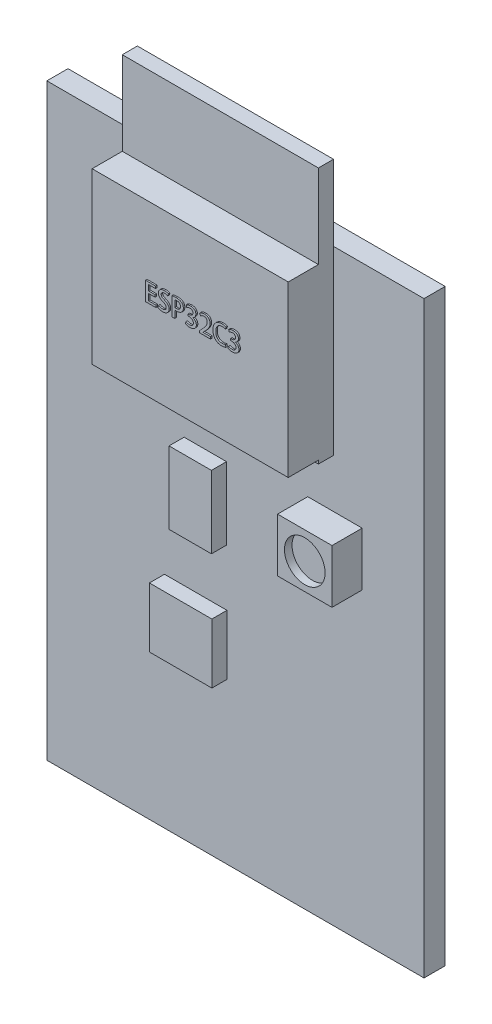
from build123d import *

# Parameters (mm, degrees)
ESQUISSE1_W             = 25
ESQUISSE1_H             = 39
BOSS_EXTRU_1_DEPTH      = 1.4
BOSS_EXTRU_2_DEPTH      = 1
ESQUISSE3_W             = 13
ESQUISSE3_H             = 11.227478687
BOSS_EXTRU_3_DEPTH      = 2
ESQUISSE4_W             = 2.809980336
ESQUISSE4_H             = 4.791755942
BOSS_EXTRU_4_DEPTH      = 1
ESQUISSE5_W             = 4.141023654
ESQUISSE5_H             = 3.963551212
BOSS_EXTRU_5_DEPTH      = 1
ESQUISSE6_W             = 3.608606328
ESQUISSE6_H             = 3.549448846
BOSS_EXTRU_6_DEPTH      = 2
ESQUISSE7_R             = 1.346751514
ENL_V_MAT_EXTRU_1_DEPTH = 0.5
BOSS_EXTRU_7_DEPTH      = 0.1


with BuildPart() as part:
    # Esquisse1 → Boss.-Extru.1 (new body)
    with BuildSketch(Plane.XY):
        with Locations((12.5, 19.5)):
            Rectangle(ESQUISSE1_W, ESQUISSE1_H)
    extrude(amount=BOSS_EXTRU_1_DEPTH)

    # Esquisse2 → Boss.-Extru.2 (add)
    with BuildSketch(Plane.XY.offset(1.4)):
        Polygon((12.5, 44), (19, 44), (19, 27), (6, 27), (6, 44), align=None)
    extrude(amount=BOSS_EXTRU_2_DEPTH)

    # Esquisse3 → Boss.-Extru.3 (add)
    with BuildSketch(Plane.XY.offset(2.4)):
        with Locations((12.5, 32.841661825)):
            Rectangle(ESQUISSE3_W, ESQUISSE3_H)
    extrude(amount=BOSS_EXTRU_3_DEPTH)

    # Esquisse4 → Boss.-Extru.4 (add)
    with BuildSketch(Plane.XY.offset(1.4)):
        with Locations((10.503435024, 20.698535423)):
            Rectangle(ESQUISSE4_W, ESQUISSE4_H)
    extrude(amount=BOSS_EXTRU_4_DEPTH)

    # Esquisse5 → Boss.-Extru.5 (add)
    with BuildSketch(Plane.XY.offset(1.4)):
        with Locations((9.867492106, 12.593960557)):
            Rectangle(ESQUISSE5_W, ESQUISSE5_H)
    extrude(amount=BOSS_EXTRU_5_DEPTH)

    # Esquisse6 → Boss.-Extru.6 (add)
    with BuildSketch(Plane.XY.offset(1.4)):
        with Locations((19.096059106, 22)):
            Rectangle(ESQUISSE6_W, ESQUISSE6_H)
    extrude(amount=BOSS_EXTRU_6_DEPTH)

    # Esquisse7 → Enlèv. mat.-Extru.1 (cut)
    with BuildSketch(Plane.XY.offset(3.4)):
        with Locations((19.096059106, 21.974927167)):
            Circle(ESQUISSE7_R)
    extrude(amount=-ENL_V_MAT_EXTRU_1_DEPTH, mode=Mode.SUBTRACT)

    # Esquisse8 → Boss.-Extru.7 (add)
    with BuildSketch(Plane.XY.offset(4.4)):
        Polygon((10.324274962, 32.843582432), (9.836071083, 32.843582432), (9.836071083, 33.266659172), (10.270750948, 33.266659172), (10.270750948, 33.414255694), (9.836071083, 33.414255694), (9.836071083, 33.77726154), (10.296701985, 33.77726154), (10.296701985, 33.924858061), (9.645533488, 33.924858061), (9.645533488, 32.695985911), (10.324274962, 32.695985911), align=None)
        with BuildLine():
            add(Edge.make_bspline(
                [(11.156073198, 33.901634395), (11.148806667, 33.90496295), (11.133481415, 33.911982936), (11.10837148, 33.921338581), (11.080088444, 33.930151407), (11.048646525, 33.93837266), (11.014149757, 33.945500766), (10.976592052, 33.950502041), (10.936020986, 33.953848147), (10.907968138, 33.954459306), (10.893412674, 33.954776411)],
                knots=[0, 0, 0, 0, 2.3972e-05, 5.0557e-05, 8.0317e-05, 0.000112815, 0.00014802, 0.000185918, 0.000226411, 0.000270079, 0.000270079, 0.000270079, 0.000270079], degree=3))
            add(Edge.make_bspline(
                [(10.893412674, 33.954776411), (10.878070628, 33.954266307), (10.848178525, 33.953272432), (10.8046434, 33.948589215), (10.763610972, 33.941105334), (10.725099188, 33.930901658), (10.689132518, 33.917671301), (10.655642631, 33.901681303), (10.624622064, 33.882959058), (10.596362877, 33.861504179), (10.570999352, 33.837870596), (10.548858082, 33.812187014), (10.529872337, 33.784785439), (10.514264075, 33.755425262), (10.502010405, 33.72416996), (10.493512939, 33.691048326), (10.487537356, 33.656274803), (10.486713418, 33.632390871), (10.486291577, 33.620162761)],
                knots=[0, 0, 0, 0, 4.604e-05, 8.9704e-05, 0.000131218, 0.000171062, 0.000209073, 0.000246017, 0.000282235, 0.000317574, 0.000352272, 0.000386046, 0.000419111, 0.000452073, 0.000485582, 0.000519561, 0.000554512, 0.000591179, 0.000591179, 0.000591179, 0.000591179], degree=3))
            add(Edge.make_bspline(
                [(10.486291577, 33.620162761), (10.486756044, 33.60982672), (10.487671023, 33.589465162), (10.491799884, 33.559555397), (10.499025609, 33.531036067), (10.508335991, 33.503516579), (10.520626882, 33.477347755), (10.535169154, 33.452266109), (10.552557978, 33.428662646), (10.572253772, 33.406204248), (10.594216055, 33.384889134), (10.617884989, 33.364418486), (10.643605449, 33.345181717), (10.67107081, 33.326934425), (10.700251916, 33.309493924), (10.731295002, 33.293114821), (10.764052207, 33.277564387), (10.78683064, 33.26838179), (10.798378643, 33.263726481)],
                knots=[0, 0, 0, 0, 3.1031e-05, 6.113e-05, 9.0382e-05, 0.000119175, 0.00014815, 0.000176965, 0.000206018, 0.00023595, 0.000266482, 0.000297762, 0.000329769, 0.000362765, 0.000396649, 0.000431709, 0.000468028, 0.000505373, 0.000505373, 0.000505373, 0.000505373], degree=3))
            add(Edge.make_bspline(
                [(10.798378643, 33.263726481), (10.807407689, 33.25997084), (10.824902148, 33.252694002), (10.84988054, 33.240805241), (10.873060364, 33.228999184), (10.89436976, 33.216709249), (10.913781159, 33.204080688), (10.931432468, 33.191274888), (10.947071004, 33.177972412), (10.961013638, 33.164443857), (10.973059766, 33.150134629), (10.983774782, 33.135461059), (10.992377864, 33.119741844), (10.999847632, 33.103607445), (11.005124204, 33.086443648), (11.009226672, 33.068745457), (11.011267242, 33.050163109), (11.011538585, 33.037604205), (11.011677246, 33.03118642)],
                knots=[0, 0, 0, 0, 2.9332e-05, 5.6834e-05, 8.2966e-05, 0.000107356, 0.000130591, 0.000152415, 0.000172726, 0.000192139, 0.000210617, 0.000228784, 0.000246539, 0.000264289, 0.000282025, 0.000300299, 0.000318724, 0.000337978, 0.000337978, 0.000337978, 0.000337978], degree=3))
            add(Edge.make_bspline(
                [(11.011677246, 33.03118642), (11.011399209, 33.024218202), (11.010856508, 33.010616926), (11.008159661, 32.990741197), (11.003054836, 32.97209707), (10.996542057, 32.954344135), (10.98807234, 32.937628173), (10.977683015, 32.922023991), (10.965307415, 32.907623096), (10.951277578, 32.894287661), (10.93548469, 32.882154135), (10.91776131, 32.872003336), (10.898622568, 32.862886927), (10.87773124, 32.855743085), (10.85526258, 32.850150232), (10.831204453, 32.845877271), (10.805467925, 32.843386105), (10.787746113, 32.84281753), (10.778667881, 32.842526269)],
                knots=[0, 0, 0, 0, 2.0917e-05, 4.0828e-05, 6.0009e-05, 7.8794e-05, 9.7474e-05, 0.000116087, 0.000134896, 0.000154315, 0.000174074, 0.000194477, 0.000215472, 0.000237587, 0.000260579, 0.000284883, 0.000310824, 0.000338069, 0.000338069, 0.000338069, 0.000338069], degree=3))
            add(Edge.make_bspline(
                [(10.778667881, 32.842526269), (10.765752057, 32.842906029), (10.74017485, 32.843658068), (10.702299788, 32.847712925), (10.665340916, 32.85420387), (10.62972148, 32.863527262), (10.59560825, 32.874025383), (10.563971298, 32.886602425), (10.534581531, 32.900040524), (10.516484988, 32.910586168), (10.507644903, 32.915737671)],
                knots=[0, 0, 0, 0, 3.8752e-05, 7.6741e-05, 0.000114163, 0.000151213, 0.000187132, 0.000221164, 0.000253286, 0.000283964, 0.000283964, 0.000283964, 0.000283964], degree=3))
            Line((10.507644903, 32.915737671), (10.465440783, 32.75736091))
            add(Edge.make_bspline(
                [(10.465440783, 32.75736091), (10.473928872, 32.752079704), (10.491787056, 32.740968518), (10.522258257, 32.727429262), (10.556799533, 32.714727798), (10.595266189, 32.703775717), (10.636309916, 32.694511539), (10.678900439, 32.68735393), (10.722657699, 32.683114002), (10.752221482, 32.682390285), (10.767169936, 32.68202435)],
                knots=[0, 0, 0, 0, 2.9959e-05, 6.3032e-05, 9.978e-05, 0.000140328, 0.000182908, 0.00022596, 0.000269809, 0.000314658, 0.000314658, 0.000314658, 0.000314658], degree=3))
            add(Edge.make_bspline(
                [(10.767169936, 32.68202435), (10.784314418, 32.682569781), (10.817668988, 32.683630917), (10.866130299, 32.689106104), (10.911501418, 32.697415444), (10.953688412, 32.708873279), (10.992799118, 32.723437961), (11.02869063, 32.741286501), (11.061625101, 32.761944915), (11.091048701, 32.785775465), (11.117066458, 32.812132597), (11.139935969, 32.840306846), (11.15937102, 32.870318903), (11.175196351, 32.902201246), (11.187387701, 32.936010555), (11.196299444, 32.971528671), (11.201847615, 33.008877801), (11.202556848, 33.034373961), (11.202918568, 33.047377403)],
                knots=[0, 0, 0, 0, 5.1442e-05, 0.000100081, 0.00014615, 0.000189698, 0.000231059, 0.000271146, 0.000309749, 0.000347459, 0.00038446, 0.000420668, 0.00045614, 0.000491505, 0.00052721, 0.000563747, 0.000601213, 0.00064021, 0.00064021, 0.00064021, 0.00064021], degree=3))
            add(Edge.make_bspline(
                [(11.202918568, 33.047377403), (11.202808349, 33.057792263), (11.202592199, 33.078216741), (11.198820859, 33.108169692), (11.193264526, 33.136987559), (11.185412662, 33.16461898), (11.174823449, 33.190881052), (11.162511638, 33.216181588), (11.147387619, 33.240032659), (11.130109172, 33.262796604), (11.110368997, 33.284412964), (11.088627105, 33.305655363), (11.064046711, 33.325738846), (11.0372426, 33.345224712), (11.0081483, 33.364035842), (10.976449031, 33.381799667), (10.942584304, 33.399265371), (10.918737459, 33.409730127), (10.906553182, 33.415076975)],
                knots=[0, 0, 0, 0, 3.1223e-05, 6.1231e-05, 9.0407e-05, 0.000119222, 0.00014724, 0.000175259, 0.000203515, 0.000231815, 0.00026089, 0.000291258, 0.000322925, 0.000356014, 0.000390641, 0.00042679, 0.000464989, 0.000504897, 0.000504897, 0.000504897, 0.000504897], degree=3))
            add(Edge.make_bspline(
                [(10.906553182, 33.415076975), (10.896976911, 33.4190683), (10.878322738, 33.426843234), (10.851703015, 33.439431675), (10.826718035, 33.451434011), (10.803981004, 33.463897242), (10.783221687, 33.476442388), (10.76424258, 33.488723382), (10.747286494, 33.501147308), (10.73229342, 33.513739787), (10.718905108, 33.526600601), (10.707683787, 33.540596108), (10.697881698, 33.55517006), (10.69008856, 33.570786536), (10.684277798, 33.58729677), (10.680038628, 33.604582005), (10.677342777, 33.622658564), (10.677157546, 33.635014461), (10.677063596, 33.641281435)],
                knots=[0, 0, 0, 0, 3.1119e-05, 6.0619e-05, 8.8324e-05, 0.000114262, 0.000138367, 0.000161081, 0.00018206, 0.000201378, 0.000219796, 0.000237644, 0.000255086, 0.000272401, 0.000289842, 0.000307485, 0.000325737, 0.000344522, 0.000344522, 0.000344522, 0.000344522], degree=3))
            add(Edge.make_bspline(
                [(10.677063596, 33.641281435), (10.677551109, 33.651517), (10.678524029, 33.671943895), (10.688179296, 33.701720879), (10.704403196, 33.729523753), (10.722564261, 33.750871905), (10.740345871, 33.76633042), (10.755990081, 33.77667051), (10.773479533, 33.785583269), (10.792796616, 33.793110608), (10.81403106, 33.798963661), (10.837229582, 33.802994043), (10.862200296, 33.80620774), (10.879557342, 33.80685), (10.888484983, 33.807180348)],
                knots=[0, 0, 0, 0, 3.0634e-05, 6.1136e-05, 9.2774e-05, 0.000126726, 0.000144695, 0.000163308, 0.000182828, 0.000203483, 0.000225401, 0.000248781, 0.000274074, 0.000300861, 0.000300861, 0.000300861, 0.000300861], degree=3))
            add(Edge.make_bspline(
                [(10.888484983, 33.807180348), (10.90100883, 33.806792894), (10.925329102, 33.80604049), (10.960390918, 33.802329444), (10.992843796, 33.796436606), (11.022447994, 33.788755349), (11.049055235, 33.779792772), (11.072520941, 33.770656649), (11.092843724, 33.761687734), (11.10487713, 33.754937466), (11.110465708, 33.751802493)],
                knots=[0, 0, 0, 0, 3.758e-05, 7.2978e-05, 0.000105656, 0.000136446, 0.000164644, 0.00018983, 0.000211988, 0.000231203, 0.000231203, 0.000231203, 0.000231203], degree=3))
            Line((11.110465708, 33.751802493), (11.156073198, 33.901634395))
        make_face()
        with BuildLine():
            Line((11.387589407, 32.698080591), (11.578127002, 32.698080591))
            Line((11.578127002, 32.698080591), (11.578127002, 33.184574307))
            add(Edge.make_bspline(
                [(11.578127002, 33.184574307), (11.586090065, 33.183161735), (11.602493748, 33.180251877), (11.628065976, 33.177880849), (11.655152299, 33.176395399), (11.673706237, 33.176422184), (11.683251066, 33.176435964)],
                knots=[0, 0, 0, 0, 2.4253e-05, 4.9959e-05, 7.6981e-05, 0.00010561, 0.00010561, 0.00010561, 0.00010561], degree=3))
            add(Edge.make_bspline(
                [(11.683251066, 33.176435964), (11.697730015, 33.176443872), (11.726350277, 33.176459504), (11.768687009, 33.180428483), (11.809959179, 33.186907014), (11.850146773, 33.196518822), (11.889230713, 33.209322032), (11.927295567, 33.224781164), (11.964259309, 33.243175514), (11.999901507, 33.264262178), (12.033174805, 33.288936813), (12.062610772, 33.318066408), (12.087547866, 33.351457132), (12.108393333, 33.388793875), (12.124991791, 33.430046479), (12.137387199, 33.475312346), (12.145646585, 33.524539565), (12.14757121, 33.558807903), (12.148565841, 33.576517502)],
                knots=[0, 0, 0, 0, 4.3416e-05, 8.582e-05, 0.000127407, 0.000168669, 0.000209631, 0.000250678, 0.000291814, 0.000333385, 0.000374778, 0.000415761, 0.000457154, 0.000499387, 0.000543702, 0.000590214, 0.000639939, 0.00069312, 0.00069312, 0.00069312, 0.00069312], degree=3))
            add(Edge.make_bspline(
                [(12.148565841, 33.576517502), (12.147955802, 33.590382856), (12.146764898, 33.617450513), (12.14082913, 33.656740555), (12.131694944, 33.693610003), (12.119301016, 33.728153899), (12.103243669, 33.760122772), (12.084091383, 33.78979844), (12.061570907, 33.81703286), (12.044040208, 33.832807136), (12.035228959, 33.840735574)],
                knots=[0, 0, 0, 0, 4.1614e-05, 8.1237e-05, 0.000118969, 0.000155416, 0.000191095, 0.000226047, 0.000261198, 0.00029672, 0.00029672, 0.00029672, 0.00029672], degree=3))
            add(Edge.make_bspline(
                [(12.035228959, 33.840735574), (12.025319532, 33.848731713), (12.00518891, 33.864975565), (11.970914603, 33.885074679), (11.933275608, 33.902124587), (11.892137233, 33.9162955), (11.847339085, 33.927023552), (11.798962369, 33.934210998), (11.747100723, 33.939168334), (11.711343741, 33.939557596), (11.692871795, 33.939758688)],
                knots=[0, 0, 0, 0, 3.8157e-05, 7.7514e-05, 0.000118781, 0.00016197, 0.000207842, 0.00025676, 0.000308596, 0.000363992, 0.000363992, 0.000363992, 0.000363992], degree=3))
            add(Edge.make_bspline(
                [(11.692871795, 33.939758688), (11.677305833, 33.93947918), (11.646951658, 33.93893413), (11.602671129, 33.937583456), (11.560813749, 33.935505728), (11.521396225, 33.932623), (11.484372742, 33.929460714), (11.449787303, 33.925464631), (11.417705318, 33.920829395), (11.397201154, 33.917130912), (11.387354984, 33.915354887)],
                knots=[0, 0, 0, 0, 4.6705e-05, 9.1077e-05, 0.000132898, 0.00017242, 0.00020964, 0.000244364, 0.000276852, 0.000306866, 0.000306866, 0.000306866, 0.000306866], degree=3))
            Line((11.387354984, 33.915354887), (11.387589407, 32.698080591))
        make_face()
        with BuildLine():
            add(Edge.make_bspline(
                [(11.578127002, 33.781077154), (11.585464044, 33.782522642), (11.602076306, 33.785795461), (11.630475666, 33.788801339), (11.665150046, 33.791100313), (11.690442408, 33.79178951), (11.704135088, 33.792162625)],
                knots=[0, 0, 0, 0, 2.2425e-05, 5.0774e-05, 8.5582e-05, 0.00012667, 0.00012667, 0.00012667, 0.00012667], degree=3))
            add(Edge.make_bspline(
                [(11.704135088, 33.792162625), (11.713448307, 33.791968122), (11.731641959, 33.791588154), (11.758245852, 33.789042364), (11.783414349, 33.784562172), (11.80718779, 33.778464228), (11.829580413, 33.770838555), (11.850438054, 33.761053698), (11.86988743, 33.749635017), (11.887794861, 33.736405), (11.904166479, 33.721682825), (11.918256268, 33.70487485), (11.930387885, 33.686402466), (11.940205011, 33.666099643), (11.947967869, 33.644137981), (11.953571599, 33.620463163), (11.957120587, 33.595081219), (11.957720388, 33.57754618), (11.958028475, 33.568539337)],
                knots=[0, 0, 0, 0, 2.7939e-05, 5.458e-05, 8.0081e-05, 0.000104553, 0.000128152, 0.000150933, 0.000173549, 0.000195701, 0.000217626, 0.000239438, 0.000261306, 0.000283764, 0.00030692, 0.000331052, 0.000356637, 0.000383659, 0.000383659, 0.000383659, 0.000383659], degree=3))
            add(Edge.make_bspline(
                [(11.958028475, 33.568539337), (11.957713586, 33.558986938), (11.957099723, 33.540364917), (11.953629682, 33.513314464), (11.94771858, 33.488026847), (11.93973225, 33.464435312), (11.929710151, 33.442445135), (11.917117863, 33.422295658), (11.902219624, 33.403945351), (11.885281314, 33.387185814), (11.86626229, 33.372429299), (11.845317547, 33.359718751), (11.822781056, 33.348586994), (11.798288795, 33.339713531), (11.772000409, 33.333028238), (11.744043247, 33.327763625), (11.714210077, 33.324791289), (11.693738354, 33.324289225), (11.683251066, 33.324032027)],
                knots=[0, 0, 0, 0, 2.8662e-05, 5.5876e-05, 8.166e-05, 0.000106444, 0.000130486, 0.000153991, 0.000177519, 0.000201246, 0.000225325, 0.000249553, 0.000274634, 0.000300616, 0.000327537, 0.000355933, 0.00038589, 0.000417355, 0.000417355, 0.000417355, 0.000417355], degree=3))
            add(Edge.make_bspline(
                [(11.683251066, 33.324032027), (11.673001313, 33.32399673), (11.653424892, 33.323929314), (11.625621696, 33.325600943), (11.600687282, 33.328347882), (11.585375927, 33.331948228), (11.578127002, 33.333652756)],
                knots=[0, 0, 0, 0, 3.074e-05, 5.8712e-05, 8.3539e-05, 0.00010586, 0.00010586, 0.00010586, 0.00010586], degree=3))
            Line((11.578127002, 33.333652756), (11.578127002, 33.781077154))
        make_face(mode=Mode.SUBTRACT)
        with BuildLine():
            add(Edge.make_bspline(
                [(12.749780747, 33.348293982), (12.758724215, 33.351364539), (12.776353656, 33.357417246), (12.801654804, 33.368143496), (12.825264112, 33.380394455), (12.847098805, 33.394048139), (12.867413753, 33.408851167), (12.886053489, 33.42500493), (12.902677097, 33.442826123), (12.918058424, 33.461475251), (12.931261239, 33.481410881), (12.942945267, 33.502003542), (12.952725205, 33.523390694), (12.961059559, 33.545355757), (12.967120878, 33.568188244), (12.971532399, 33.59163891), (12.974499213, 33.615864242), (12.974838411, 33.632277692), (12.975009934, 33.640577479)],
                knots=[0, 0, 0, 0, 2.8362e-05, 5.5907e-05, 8.2355e-05, 0.000108074, 0.00013309, 0.000157702, 0.000181936, 0.000206124, 0.000230139, 0.000253569, 0.000277087, 0.000300623, 0.000323961, 0.000347846, 0.000372179, 0.00039707, 0.00039707, 0.00039707, 0.00039707], degree=3))
            add(Edge.make_bspline(
                [(12.975009934, 33.640577479), (12.974833476, 33.650916287), (12.974487178, 33.671206242), (12.970307002, 33.70097553), (12.963749731, 33.72948835), (12.954727971, 33.75679955), (12.942528886, 33.782574641), (12.927909572, 33.807086802), (12.91074327, 33.830461844), (12.890754854, 33.852230021), (12.868263522, 33.872375867), (12.842707051, 33.889714966), (12.814608548, 33.904576067), (12.783798952, 33.916719791), (12.750393963, 33.926695711), (12.714116573, 33.933432423), (12.675249337, 33.938316957), (12.648390406, 33.939267938), (12.634529985, 33.939758688)],
                knots=[0, 0, 0, 0, 3.0996e-05, 6.083e-05, 8.9973e-05, 0.00011869, 0.000146929, 0.00017534, 0.000204203, 0.000233767, 0.000263855, 0.000294576, 0.000326171, 0.000359026, 0.000393773, 0.000430589, 0.00046959, 0.000511177, 0.000511177, 0.000511177, 0.000511177], degree=3))
            add(Edge.make_bspline(
                [(12.634529985, 33.939758688), (12.618795486, 33.939272063), (12.587792417, 33.938313223), (12.542270764, 33.933163846), (12.498699333, 33.924633495), (12.45748922, 33.913458177), (12.419340769, 33.900243566), (12.385011982, 33.885593729), (12.354345485, 33.870516933), (12.336403329, 33.858299361), (12.327839914, 33.85246817)],
                knots=[0, 0, 0, 0, 4.7212e-05, 9.3027e-05, 0.000137251, 0.000180285, 0.000221026, 0.000258246, 0.000292248, 0.000323294, 0.000323294, 0.000323294, 0.000323294], degree=3))
            Line((12.327839914, 33.85246817), (12.375083093, 33.714772173))
            add(Edge.make_bspline(
                [(12.375083093, 33.714772173), (12.381477238, 33.719402751), (12.394861482, 33.729095491), (12.417262765, 33.742011819), (12.442177922, 33.754683057), (12.469360851, 33.766758674), (12.49824015, 33.777752437), (12.528826822, 33.785287556), (12.560193258, 33.790744673), (12.581553701, 33.791688245), (12.592292638, 33.792162625)],
                knots=[0, 0, 0, 0, 2.3671e-05, 4.9547e-05, 7.7462e-05, 0.000107506, 0.00013876, 0.000170005, 0.000201869, 0.000234086, 0.000234086, 0.000234086, 0.000234086], degree=3))
            add(Edge.make_bspline(
                [(12.592292638, 33.792162625), (12.6001228, 33.791896155), (12.61536379, 33.791377485), (12.637429269, 33.788558238), (12.657909155, 33.784104218), (12.676767017, 33.778247597), (12.694193082, 33.771015252), (12.70987796, 33.761811078), (12.724097166, 33.751151107), (12.736799324, 33.739204229), (12.747825795, 33.725942787), (12.757499518, 33.711805892), (12.765740762, 33.696818582), (12.772287022, 33.680964441), (12.777537833, 33.66433443), (12.781262563, 33.646818977), (12.783366862, 33.628427539), (12.783633283, 33.615944312), (12.783768612, 33.609603424)],
                knots=[0, 0, 0, 0, 2.3495e-05, 4.5731e-05, 6.6627e-05, 8.6294e-05, 0.000104904, 0.000123095, 0.000140694, 0.000158123, 0.000175279, 0.000192331, 0.000209448, 0.000226487, 0.000243705, 0.0002617, 0.000280124, 0.000299144, 0.000299144, 0.000299144, 0.000299144], degree=3))
            add(Edge.make_bspline(
                [(12.783768612, 33.609603424), (12.783169203, 33.600978079), (12.782000396, 33.584159214), (12.777227471, 33.559844953), (12.770231302, 33.537254301), (12.760984706, 33.516406089), (12.749756973, 33.497197484), (12.73592908, 33.479905885), (12.719872419, 33.464355034), (12.695857576, 33.446236861), (12.663856122, 33.427584761), (12.623583453, 33.4114747), (12.58243062, 33.400926934), (12.554419584, 33.399878664), (12.540434562, 33.399355296)],
                knots=[0, 0, 0, 0, 2.5918e-05, 5.0539e-05, 7.414e-05, 9.6726e-05, 0.000118819, 0.000140698, 0.000162934, 0.000185696, 0.000230811, 0.000273557, 0.000315559, 0.000357438, 0.000357438, 0.000357438, 0.000357438], degree=3))
            Line((12.540434562, 33.399355296), (12.461045902, 33.399589719))
            Line((12.461045902, 33.399589719), (12.461045902, 33.281325147))
            Line((12.461045902, 33.281325147), (12.543764832, 33.281325147))
            add(Edge.make_bspline(
                [(12.543764832, 33.281325147), (12.552437732, 33.281127194), (12.569601985, 33.280735431), (12.595010855, 33.278147631), (12.619558805, 33.273714955), (12.643219687, 33.267518468), (12.666161836, 33.259878456), (12.688127512, 33.249921984), (12.709321316, 33.238413661), (12.729509456, 33.225303071), (12.748424717, 33.210573373), (12.764559606, 33.193126228), (12.778925884, 33.174265181), (12.790665258, 33.153254919), (12.799826196, 33.130266886), (12.806533352, 33.105370159), (12.811393925, 33.078683608), (12.812367288, 33.06014865), (12.812865451, 33.05066253)],
                knots=[0, 0, 0, 0, 2.6018e-05, 5.1492e-05, 7.653e-05, 0.000100776, 0.000124818, 0.000148977, 0.000173023, 0.000197104, 0.000221144, 0.000244715, 0.00026818, 0.000292134, 0.000316666, 0.000342227, 0.000369386, 0.000397857, 0.000397857, 0.000397857, 0.000397857], degree=3))
            add(Edge.make_bspline(
                [(12.812865451, 33.05066253), (12.812775621, 33.043613166), (12.812598312, 33.029698977), (12.809824537, 33.009229765), (12.805767122, 32.989272363), (12.79919858, 32.970060209), (12.791401153, 32.951120065), (12.781054847, 32.933089697), (12.769388006, 32.915394961), (12.755770493, 32.89846413), (12.740194457, 32.882676216), (12.722064643, 32.868937889), (12.701757192, 32.857253706), (12.679305595, 32.847279698), (12.654530571, 32.839684493), (12.627683948, 32.83387377), (12.598665641, 32.829771019), (12.578540609, 32.828898689), (12.568123489, 32.828447153)],
                knots=[0, 0, 0, 0, 2.113e-05, 4.1708e-05, 6.1866e-05, 8.2124e-05, 0.000102521, 0.000123215, 0.000144367, 0.000166061, 0.000188295, 0.000210729, 0.000234072, 0.000258445, 0.000284272, 0.000311658, 0.000340794, 0.000372059, 0.000372059, 0.000372059, 0.000372059], degree=3))
            add(Edge.make_bspline(
                [(12.568123489, 32.828447153), (12.555515916, 32.828959079), (12.530689069, 32.829967162), (12.494290094, 32.83475305), (12.459357331, 32.841969438), (12.426443902, 32.851833722), (12.396257354, 32.862996601), (12.36934638, 32.874217431), (12.346176594, 32.885433994), (12.332698044, 32.894106852), (12.326432003, 32.898138776)],
                knots=[0, 0, 0, 0, 3.7838e-05, 7.4511e-05, 0.000109993, 0.00014474, 0.000177478, 0.000206503, 0.000232213, 0.000254549, 0.000254549, 0.000254549, 0.000254549], degree=3))
            Line((12.326432003, 32.898138776), (12.277796266, 32.755562294))
            add(Edge.make_bspline(
                [(12.277796266, 32.755562294), (12.285857131, 32.750585616), (12.302949301, 32.740033122), (12.332036011, 32.727056824), (12.365078069, 32.71454696), (12.401963822, 32.703229488), (12.442127398, 32.69358522), (12.484876044, 32.686679245), (12.529780561, 32.68212245), (12.560447066, 32.681280756), (12.576101655, 32.68085109)],
                knots=[0, 0, 0, 0, 2.8393e-05, 6.0203e-05, 9.533e-05, 0.000134371, 0.000175862, 0.000219145, 0.000264185, 0.000311152, 0.000311152, 0.000311152, 0.000311152], degree=3))
            add(Edge.make_bspline(
                [(12.576101655, 32.68085109), (12.593012122, 32.681476574), (12.625905269, 32.682693224), (12.673599495, 32.688353803), (12.718234587, 32.69703266), (12.75989038, 32.708543933), (12.79828876, 32.723746312), (12.833844596, 32.741490651), (12.866153149, 32.762751125), (12.895238754, 32.786950835), (12.921028991, 32.813452564), (12.943488429, 32.84178168), (12.962534176, 32.871692092), (12.978448745, 32.903060583), (12.990718632, 32.936129498), (12.999292827, 32.970852608), (13.004909665, 33.007070935), (13.005622502, 33.0317911), (13.005983988, 33.044326928)],
                knots=[0, 0, 0, 0, 5.075e-05, 9.8717e-05, 0.000143908, 0.000187066, 0.000228157, 0.000267615, 0.000306079, 0.000343904, 0.000380909, 0.000416823, 0.000452169, 0.000487114, 0.000522158, 0.000557728, 0.000594265, 0.000631856, 0.000631856, 0.000631856, 0.000631856], degree=3))
            add(Edge.make_bspline(
                [(13.005983988, 33.044326928), (13.005519601, 33.054898683), (13.004615219, 33.075486853), (13.000585106, 33.105558665), (12.994313615, 33.133907872), (12.98575266, 33.16065213), (12.975369877, 33.185867358), (12.962185076, 33.209212581), (12.94732706, 33.231225429), (12.929748498, 33.25097279), (12.911069547, 33.269323267), (12.891077928, 33.285747848), (12.870027138, 33.300375249), (12.84807482, 33.313367588), (12.824863119, 33.324058134), (12.800899456, 33.333419794), (12.775690944, 33.340360971), (12.758450171, 33.343699495), (12.749744082, 33.345385352)],
                knots=[0, 0, 0, 0, 3.1734e-05, 6.18e-05, 9.0891e-05, 0.00011872, 0.000145958, 0.000172533, 0.000199023, 0.000225468, 0.000251687, 0.000277525, 0.000302977, 0.000328532, 0.000353935, 0.00037956, 0.000405636, 0.000432235, 0.000432235, 0.000432235, 0.000432235], degree=3))
            Line((12.749744082, 33.345385352), (12.749780747, 33.348293982))
        make_face()
        with BuildLine():
            Line((13.946842666, 32.843582432), (13.453002558, 32.843582432))
            Line((13.453002558, 32.843582432), (13.453002558, 32.846882225))
            Line((13.453002558, 32.846882225), (13.553562825, 32.950825696))
            add(Edge.make_bspline(
                [(13.553562825, 32.950825696), (13.566797082, 32.964099949), (13.592962069, 32.990344011), (13.630660567, 33.030245713), (13.666623984, 33.069797816), (13.700409534, 33.109379632), (13.732512016, 33.148410835), (13.762769643, 33.187150084), (13.790460072, 33.226014627), (13.817084905, 33.264083204), (13.840809517, 33.302543446), (13.861666683, 33.34141819), (13.879234342, 33.380889407), (13.893946375, 33.420819382), (13.90512707, 33.461443849), (13.913692288, 33.502403818), (13.918897266, 33.544009776), (13.92006847, 33.571889224), (13.920657207, 33.585903579)],
                knots=[0, 0, 0, 0, 5.6231e-05, 0.000111172, 0.000164665, 0.000216587, 0.000267272, 0.000316274, 0.000364011, 0.000410418, 0.000455613, 0.000499493, 0.000542665, 0.000585126, 0.000627028, 0.000668952, 0.000710572, 0.00075264, 0.00075264, 0.00075264, 0.00075264], degree=3))
            add(Edge.make_bspline(
                [(13.920657207, 33.585903579), (13.920483622, 33.597806079), (13.920142271, 33.621212262), (13.915900656, 33.655637726), (13.909586199, 33.688864406), (13.899749058, 33.720585346), (13.88766645, 33.751125108), (13.872232564, 33.779995296), (13.854264163, 33.807631839), (13.833810031, 33.833956932), (13.810095794, 33.858006422), (13.78309458, 33.879011214), (13.752998355, 33.896983258), (13.719715276, 33.911731055), (13.683331711, 33.923356379), (13.643954034, 33.932347544), (13.601366152, 33.937906685), (13.571902356, 33.939128679), (13.556712065, 33.939758688)],
                knots=[0, 0, 0, 0, 3.5686e-05, 7.0177e-05, 0.000103909, 0.000137016, 0.000169653, 0.000202297, 0.000235035, 0.000268458, 0.000302141, 0.000336078, 0.000370807, 0.000407045, 0.000445039, 0.000485227, 0.000528071, 0.000573667, 0.000573667, 0.000573667, 0.000573667], degree=3))
            add(Edge.make_bspline(
                [(13.556712065, 33.939758688), (13.539876912, 33.939161184), (13.506959759, 33.937992906), (13.4586629, 33.9318153), (13.412684156, 33.921871607), (13.369377876, 33.907808281), (13.328847035, 33.891603722), (13.291757271, 33.872860043), (13.257647557, 33.853065156), (13.237361449, 33.837507814), (13.227495409, 33.829941585)],
                knots=[0, 0, 0, 0, 5.0516e-05, 9.8772e-05, 0.000145858, 0.000191423, 0.000235215, 0.000276666, 0.000316023, 0.000353288, 0.000353288, 0.000353288, 0.000353288], degree=3))
            Line((13.227495409, 33.829941585), (13.284320819, 33.694928961))
            add(Edge.make_bspline(
                [(13.284320819, 33.694928961), (13.291732634, 33.700935642), (13.306934335, 33.713255401), (13.331881012, 33.730005518), (13.358995089, 33.745901819), (13.38779607, 33.761240914), (13.418481556, 33.774477459), (13.450919756, 33.784093418), (13.484675311, 33.790382087), (13.507720869, 33.791563686), (13.519402408, 33.792162625)],
                knots=[0, 0, 0, 0, 2.8609e-05, 5.8678e-05, 9.0027e-05, 0.000122879, 0.000156525, 0.000190081, 0.000224187, 0.000259245, 0.000259245, 0.000259245, 0.000259245], degree=3))
            add(Edge.make_bspline(
                [(13.519402408, 33.792162625), (13.528569888, 33.791792347), (13.546354125, 33.791074035), (13.571900993, 33.787127452), (13.595558137, 33.781957399), (13.617154911, 33.774401744), (13.636611522, 33.764734111), (13.654295533, 33.75348383), (13.669666648, 33.739979432), (13.682776381, 33.724521071), (13.694250708, 33.707879882), (13.704086121, 33.690141188), (13.712633205, 33.671704174), (13.719145904, 33.652217922), (13.724297152, 33.631982302), (13.728170349, 33.610832992), (13.729924016, 33.588750787), (13.730053959, 33.573782041), (13.73011984, 33.566192817)],
                knots=[0, 0, 0, 0, 2.7503e-05, 5.3355e-05, 7.7432e-05, 0.000100067, 0.00012179, 0.000142488, 0.000162774, 0.000182906, 0.000203149, 0.000223319, 0.000243691, 0.000264023, 0.000284853, 0.000306303, 0.00032844, 0.000351206, 0.000351206, 0.000351206, 0.000351206], degree=3))
            add(Edge.make_bspline(
                [(13.73011984, 33.566192817), (13.729708808, 33.554754842), (13.728880352, 33.531701053), (13.723648647, 33.497029876), (13.715885777, 33.461997759), (13.703980444, 33.426845328), (13.689574776, 33.39126308), (13.671757937, 33.355398366), (13.650867496, 33.319246508), (13.626439711, 33.282781387), (13.598863729, 33.245509363), (13.569266751, 33.20618433), (13.536215791, 33.165710784), (13.500588007, 33.123359405), (13.461782087, 33.079682351), (13.420582086, 33.033994612), (13.376050845, 32.987138818), (13.345318397, 32.955444956), (13.329568998, 32.939202864)],
                knots=[0, 0, 0, 0, 3.4311e-05, 6.9155e-05, 0.000105016, 0.000141822, 0.000180342, 0.000220114, 0.000261851, 0.000305521, 0.000351704, 0.000400935, 0.000453157, 0.00050844, 0.000566959, 0.000628423, 0.000692994, 0.000760866, 0.000760866, 0.000760866, 0.000760866], degree=3))
            Line((13.329568998, 32.939202864), (13.20160189, 32.805140076))
            Line((13.20160189, 32.805140076), (13.20160189, 32.695985911))
            Line((13.20160189, 32.695985911), (13.946842666, 32.695985911))
            Line((13.946842666, 32.695985911), (13.946842666, 32.843582432))
        make_face()
        with BuildLine():
            add(Edge.make_bspline(
                [(14.935379224, 32.886529005), (14.928120852, 32.883248785), (14.913149079, 32.876482706), (14.888980614, 32.868157454), (14.86275934, 32.860625861), (14.824521969, 32.852265558), (14.773909112, 32.844494245), (14.732508753, 32.843190123), (14.711434206, 32.842526269)],
                knots=[0, 0, 0, 0, 2.3884e-05, 4.9266e-05, 7.6598e-05, 0.00010569, 0.000166651, 0.000229858, 0.000229858, 0.000229858, 0.000229858], degree=3))
            add(Edge.make_bspline(
                [(14.711434206, 32.842526269), (14.695694389, 32.842950544), (14.664962917, 32.843778926), (14.620152639, 32.849690579), (14.578012545, 32.859497569), (14.538515082, 32.873158497), (14.501658835, 32.890584076), (14.467431371, 32.911853878), (14.435706839, 32.936810265), (14.407110864, 32.965920962), (14.381173469, 32.998260358), (14.358794976, 33.034315684), (14.339755135, 33.073632432), (14.324302434, 33.116449905), (14.312167547, 33.162560499), (14.303380728, 33.211999393), (14.29758941, 33.26476524), (14.296761353, 33.30109848), (14.296334945, 33.319808292)],
                knots=[0, 0, 0, 0, 4.7212e-05, 9.218e-05, 0.000135324, 0.000176807, 0.000217322, 0.000257368, 0.00029746, 0.000338112, 0.000379522, 0.000421582, 0.000465136, 0.000510343, 0.000557926, 0.000608003, 0.000660866, 0.000716988, 0.000716988, 0.000716988, 0.000716988], degree=3))
            add(Edge.make_bspline(
                [(14.296334945, 33.319808292), (14.296918497, 33.339458271), (14.29805121, 33.377600148), (14.304260201, 33.432880879), (14.313627031, 33.484511411), (14.327127594, 33.532162373), (14.343428032, 33.576323722), (14.363610118, 33.616568802), (14.387440144, 33.653051247), (14.414784179, 33.685511342), (14.44490805, 33.714027383), (14.476917011, 33.739281001), (14.511444807, 33.760171359), (14.54800708, 33.777416286), (14.586721684, 33.79080937), (14.627505973, 33.800451118), (14.670443172, 33.806142823), (14.69976262, 33.806829867), (14.714719333, 33.807180348)],
                knots=[0, 0, 0, 0, 5.8954e-05, 0.000114434, 0.000166715, 0.000216192, 0.000262826, 0.00030774, 0.000350955, 0.000393257, 0.00043475, 0.000475211, 0.000515334, 0.000555537, 0.000596278, 0.000637997, 0.000681073, 0.000725931, 0.000725931, 0.000725931, 0.000725931], degree=3))
            add(Edge.make_bspline(
                [(14.714719333, 33.807180348), (14.725988154, 33.80699429), (14.747930389, 33.806632003), (14.779892154, 33.803995702), (14.810008418, 33.799896587), (14.838130487, 33.793860489), (14.864481661, 33.787180738), (14.888751771, 33.779331321), (14.911306745, 33.771324833), (14.925246402, 33.76481506), (14.93200702, 33.761657874)],
                knots=[0, 0, 0, 0, 3.3803e-05, 6.582e-05, 9.6151e-05, 0.000124914, 0.000152061, 0.000177664, 0.000201421, 0.000223793, 0.000223793, 0.000223793, 0.000223793], degree=3))
            Line((14.93200702, 33.761657874), (14.97268384, 33.90924225))
            add(Edge.make_bspline(
                [(14.97268384, 33.90924225), (14.967603821, 33.911590071), (14.955963258, 33.916969962), (14.935506132, 33.924030634), (14.910001455, 33.931171487), (14.879637017, 33.938746021), (14.844053675, 33.945630646), (14.803292884, 33.950597003), (14.757398932, 33.953871455), (14.725128354, 33.954464421), (14.708149079, 33.954776411)],
                knots=[0, 0, 0, 0, 1.6781e-05, 3.8453e-05, 6.4819e-05, 9.6234e-05, 0.000132314, 0.000173469, 0.000219344, 0.000270283, 0.000270283, 0.000270283, 0.000270283], degree=3))
            add(Edge.make_bspline(
                [(14.708149079, 33.954776411), (14.686693197, 33.954303485), (14.644653278, 33.953376848), (14.583074581, 33.945429952), (14.524548518, 33.932617875), (14.468934363, 33.914735039), (14.416444255, 33.891639199), (14.366822926, 33.863622191), (14.320385955, 33.830290441), (14.277145671, 33.792064546), (14.237848149, 33.748854143), (14.203257073, 33.700606797), (14.174195416, 33.647252217), (14.150276225, 33.589135384), (14.131245177, 33.526265142), (14.117334137, 33.458568963), (14.108354625, 33.385972831), (14.106511835, 33.335947239), (14.105562926, 33.310187563)],
                knots=[0, 0, 0, 0, 6.4346e-05, 0.000126078, 0.000185915, 0.00024387, 0.000301027, 0.000357666, 0.000414513, 0.000472194, 0.000530502, 0.000589367, 0.000649856, 0.000712346, 0.000777593, 0.000846624, 0.000919445, 0.000996748, 0.000996748, 0.000996748, 0.000996748], degree=3))
            add(Edge.make_bspline(
                [(14.105562926, 33.310187563), (14.106185654, 33.28583636), (14.107396502, 33.238487262), (14.115706005, 33.169653685), (14.127792351, 33.105070332), (14.145017317, 33.044743169), (14.166795175, 32.988776133), (14.193097627, 32.936861562), (14.224540398, 32.889541326), (14.260206596, 32.846371193), (14.300238205, 32.808189759), (14.34358563, 32.774525573), (14.390572671, 32.746280261), (14.440968432, 32.723165846), (14.494783812, 32.705092212), (14.552068147, 32.691986216), (14.612812665, 32.683946943), (14.654467341, 32.682674833), (14.675767113, 32.68202435)],
                knots=[0, 0, 0, 0, 7.304e-05, 0.000142022, 0.000207739, 0.000269978, 0.000329938, 0.000387657, 0.000444212, 0.000500034, 0.000555299, 0.000609838, 0.000664366, 0.000719384, 0.000775853, 0.000834368, 0.000895431, 0.00095933, 0.00095933, 0.00095933, 0.00095933], degree=3))
            add(Edge.make_bspline(
                [(14.675767113, 32.68202435), (14.692200077, 32.682236408), (14.723927162, 32.682645828), (14.769867606, 32.68614663), (14.812503251, 32.690834869), (14.851660648, 32.697621984), (14.886823102, 32.705875738), (14.917900755, 32.714404312), (14.944567855, 32.723575489), (14.960371914, 32.730946148), (14.967674113, 32.73435173)],
                knots=[0, 0, 0, 0, 4.9291e-05, 9.5166e-05, 0.000138156, 0.000177929, 0.000214301, 0.000246469, 0.000274597, 0.000298756, 0.000298756, 0.000298756, 0.000298756], degree=3))
            Line((14.967674113, 32.73435173), (14.935379224, 32.886529005))
        make_face()
        with BuildLine():
            add(Edge.make_bspline(
                [(15.573112753, 33.348293982), (15.582056222, 33.351364539), (15.599685663, 33.357417246), (15.624986811, 33.368143496), (15.648596119, 33.380394455), (15.670430812, 33.394048139), (15.690745759, 33.408851167), (15.709385495, 33.42500493), (15.726009104, 33.442826123), (15.741390431, 33.461475251), (15.754593246, 33.481410881), (15.766277274, 33.502003542), (15.776057211, 33.523390694), (15.784391565, 33.545355757), (15.790452884, 33.568188244), (15.794864405, 33.59163891), (15.79783122, 33.615864242), (15.798170418, 33.632277692), (15.79834194, 33.640577479)],
                knots=[0, 0, 0, 0, 2.8362e-05, 5.5907e-05, 8.2355e-05, 0.000108074, 0.00013309, 0.000157702, 0.000181936, 0.000206124, 0.000230139, 0.000253569, 0.000277087, 0.000300623, 0.000323961, 0.000347846, 0.000372179, 0.00039707, 0.00039707, 0.00039707, 0.00039707], degree=3))
            add(Edge.make_bspline(
                [(15.79834194, 33.640577479), (15.798165483, 33.650916287), (15.797819185, 33.671206242), (15.793639009, 33.70097553), (15.787081738, 33.72948835), (15.778059978, 33.75679955), (15.765860893, 33.782574641), (15.751241579, 33.807086802), (15.734075277, 33.830461844), (15.71408686, 33.852230021), (15.691595528, 33.872375867), (15.666039058, 33.889714966), (15.637940554, 33.904576067), (15.607130958, 33.916719791), (15.573725969, 33.926695711), (15.53744858, 33.933432423), (15.498581344, 33.938316957), (15.471722413, 33.939267938), (15.457861992, 33.939758688)],
                knots=[0, 0, 0, 0, 3.0996e-05, 6.083e-05, 8.9973e-05, 0.00011869, 0.000146929, 0.00017534, 0.000204203, 0.000233767, 0.000263855, 0.000294576, 0.000326171, 0.000359026, 0.000393773, 0.000430589, 0.00046959, 0.000511177, 0.000511177, 0.000511177, 0.000511177], degree=3))
            add(Edge.make_bspline(
                [(15.457861992, 33.939758688), (15.442127493, 33.939272063), (15.411124423, 33.938313223), (15.365602771, 33.933163846), (15.32203134, 33.924633495), (15.280821226, 33.913458177), (15.242672776, 33.900243566), (15.208343989, 33.885593729), (15.177677492, 33.870516933), (15.159735336, 33.858299361), (15.151171921, 33.85246817)],
                knots=[0, 0, 0, 0, 4.7212e-05, 9.3027e-05, 0.000137251, 0.000180285, 0.000221026, 0.000258246, 0.000292248, 0.000323294, 0.000323294, 0.000323294, 0.000323294], degree=3))
            Line((15.151171921, 33.85246817), (15.1984151, 33.714772173))
            add(Edge.make_bspline(
                [(15.1984151, 33.714772173), (15.204809245, 33.719402751), (15.218193489, 33.729095491), (15.240594772, 33.742011819), (15.265509928, 33.754683057), (15.292692858, 33.766758674), (15.321572156, 33.777752437), (15.352158829, 33.785287556), (15.383525264, 33.790744673), (15.404885707, 33.791688245), (15.415624645, 33.792162625)],
                knots=[0, 0, 0, 0, 2.3671e-05, 4.9547e-05, 7.7462e-05, 0.000107506, 0.00013876, 0.000170005, 0.000201869, 0.000234086, 0.000234086, 0.000234086, 0.000234086], degree=3))
            add(Edge.make_bspline(
                [(15.415624645, 33.792162625), (15.423454807, 33.791896155), (15.438695797, 33.791377485), (15.460761275, 33.788558238), (15.481241162, 33.784104218), (15.500099024, 33.778247597), (15.517525089, 33.771015252), (15.533209966, 33.761811078), (15.547429173, 33.751151107), (15.560131331, 33.739204229), (15.571157802, 33.725942787), (15.580831524, 33.711805892), (15.589072769, 33.696818582), (15.595619029, 33.680964441), (15.600869839, 33.66433443), (15.60459457, 33.646818977), (15.606698868, 33.628427539), (15.606965289, 33.615944312), (15.607100619, 33.609603424)],
                knots=[0, 0, 0, 0, 2.3495e-05, 4.5731e-05, 6.6627e-05, 8.6294e-05, 0.000104904, 0.000123095, 0.000140694, 0.000158123, 0.000175279, 0.000192331, 0.000209448, 0.000226487, 0.000243705, 0.0002617, 0.000280124, 0.000299144, 0.000299144, 0.000299144, 0.000299144], degree=3))
            add(Edge.make_bspline(
                [(15.607100619, 33.609603424), (15.60650121, 33.600978079), (15.605332402, 33.584159214), (15.600559478, 33.559844953), (15.593563309, 33.537254301), (15.584316712, 33.516406089), (15.57308898, 33.497197484), (15.559261087, 33.479905885), (15.543204425, 33.464355034), (15.519189583, 33.446236861), (15.487188129, 33.427584761), (15.44691546, 33.4114747), (15.405762626, 33.400926934), (15.377751591, 33.399878664), (15.363766568, 33.399355296)],
                knots=[0, 0, 0, 0, 2.5918e-05, 5.0539e-05, 7.414e-05, 9.6726e-05, 0.000118819, 0.000140698, 0.000162934, 0.000185696, 0.000230811, 0.000273557, 0.000315559, 0.000357438, 0.000357438, 0.000357438, 0.000357438], degree=3))
            Line((15.363766568, 33.399355296), (15.284377909, 33.399589719))
            Line((15.284377909, 33.399589719), (15.284377909, 33.281325147))
            Line((15.284377909, 33.281325147), (15.367096838, 33.281325147))
            add(Edge.make_bspline(
                [(15.367096838, 33.281325147), (15.375769739, 33.281127194), (15.392933992, 33.280735431), (15.418342862, 33.278147631), (15.442890812, 33.273714955), (15.466551694, 33.267518468), (15.489493842, 33.259878456), (15.511459519, 33.249921984), (15.532653323, 33.238413661), (15.552841462, 33.225303071), (15.571756723, 33.210573373), (15.587891613, 33.193126228), (15.60225789, 33.174265181), (15.613997265, 33.153254919), (15.623158203, 33.130266886), (15.629865359, 33.105370159), (15.634725932, 33.078683608), (15.635699294, 33.06014865), (15.636197458, 33.05066253)],
                knots=[0, 0, 0, 0, 2.6018e-05, 5.1492e-05, 7.653e-05, 0.000100776, 0.000124818, 0.000148977, 0.000173023, 0.000197104, 0.000221144, 0.000244715, 0.00026818, 0.000292134, 0.000316666, 0.000342227, 0.000369386, 0.000397857, 0.000397857, 0.000397857, 0.000397857], degree=3))
            add(Edge.make_bspline(
                [(15.636197458, 33.05066253), (15.636107628, 33.043613166), (15.635930319, 33.029698977), (15.633156544, 33.009229765), (15.629099128, 32.989272363), (15.622530587, 32.970060209), (15.614733159, 32.951120065), (15.604386853, 32.933089697), (15.592720013, 32.915394961), (15.5791025, 32.89846413), (15.563526464, 32.882676216), (15.54539665, 32.868937889), (15.525089199, 32.857253706), (15.502637602, 32.847279698), (15.477862577, 32.839684493), (15.451015955, 32.83387377), (15.421997648, 32.829771019), (15.401872616, 32.828898689), (15.391455496, 32.828447153)],
                knots=[0, 0, 0, 0, 2.113e-05, 4.1708e-05, 6.1866e-05, 8.2124e-05, 0.000102521, 0.000123215, 0.000144367, 0.000166061, 0.000188295, 0.000210729, 0.000234072, 0.000258445, 0.000284272, 0.000311658, 0.000340794, 0.000372059, 0.000372059, 0.000372059, 0.000372059], degree=3))
            add(Edge.make_bspline(
                [(15.391455496, 32.828447153), (15.378847923, 32.828959079), (15.354021076, 32.829967162), (15.3176221, 32.83475305), (15.282689338, 32.841969438), (15.249775909, 32.851833722), (15.219589361, 32.862996601), (15.192678387, 32.874217431), (15.169508601, 32.885433994), (15.156030051, 32.894106852), (15.149764009, 32.898138776)],
                knots=[0, 0, 0, 0, 3.7838e-05, 7.4511e-05, 0.000109993, 0.00014474, 0.000177478, 0.000206503, 0.000232213, 0.000254549, 0.000254549, 0.000254549, 0.000254549], degree=3))
            Line((15.149764009, 32.898138776), (15.101128272, 32.755562294))
            add(Edge.make_bspline(
                [(15.101128272, 32.755562294), (15.109189137, 32.750585616), (15.126281307, 32.740033122), (15.155368018, 32.727056824), (15.188410076, 32.71454696), (15.225295828, 32.703229488), (15.265459405, 32.69358522), (15.30820805, 32.686679245), (15.353112568, 32.68212245), (15.383779073, 32.681280756), (15.399433662, 32.68085109)],
                knots=[0, 0, 0, 0, 2.8393e-05, 6.0203e-05, 9.533e-05, 0.000134371, 0.000175862, 0.000219145, 0.000264185, 0.000311152, 0.000311152, 0.000311152, 0.000311152], degree=3))
            add(Edge.make_bspline(
                [(15.399433662, 32.68085109), (15.416344129, 32.681476574), (15.449237276, 32.682693224), (15.496931502, 32.688353803), (15.541566594, 32.69703266), (15.583222387, 32.708543933), (15.621620767, 32.723746312), (15.657176602, 32.741490651), (15.689485155, 32.762751125), (15.71857076, 32.786950835), (15.744360998, 32.813452564), (15.766820436, 32.84178168), (15.785866183, 32.871692092), (15.801780752, 32.903060583), (15.814050639, 32.936129498), (15.822624834, 32.970852608), (15.828241671, 33.007070935), (15.828954509, 33.0317911), (15.829315995, 33.044326928)],
                knots=[0, 0, 0, 0, 5.075e-05, 9.8717e-05, 0.000143908, 0.000187066, 0.000228157, 0.000267615, 0.000306079, 0.000343904, 0.000380909, 0.000416823, 0.000452169, 0.000487114, 0.000522158, 0.000557728, 0.000594265, 0.000631856, 0.000631856, 0.000631856, 0.000631856], degree=3))
            add(Edge.make_bspline(
                [(15.829315995, 33.044326928), (15.828851607, 33.054898683), (15.827947226, 33.075486853), (15.823917113, 33.105558665), (15.817645622, 33.133907872), (15.809084666, 33.16065213), (15.798701884, 33.185867358), (15.785517083, 33.209212581), (15.770659067, 33.231225429), (15.753080505, 33.25097279), (15.734401554, 33.269323267), (15.714409934, 33.285747848), (15.693359145, 33.300375249), (15.671406827, 33.313367588), (15.648195125, 33.324058134), (15.624231463, 33.333419794), (15.599022951, 33.340360971), (15.581782178, 33.343699495), (15.573076089, 33.345385352)],
                knots=[0, 0, 0, 0, 3.1734e-05, 6.18e-05, 9.0891e-05, 0.00011872, 0.000145958, 0.000172533, 0.000199023, 0.000225468, 0.000251687, 0.000277525, 0.000302977, 0.000328532, 0.000353935, 0.00037956, 0.000405636, 0.000432235, 0.000432235, 0.000432235, 0.000432235], degree=3))
            Line((15.573076089, 33.345385352), (15.573112753, 33.348293982))
        make_face()
    extrude(amount=BOSS_EXTRU_7_DEPTH)


solid = part.part
